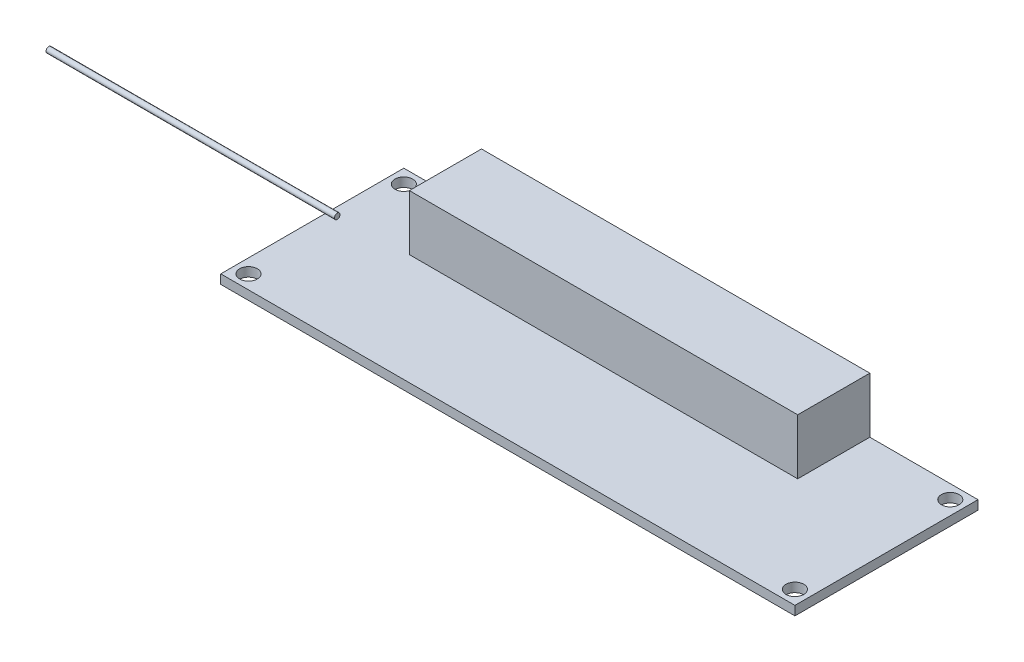
from build123d import *

# Parameters (mm, degrees)
SKIZZE1_W                            = 103.5
SKIZZE1_H                            = 33
AUFSATZ_LINEAR_AUSTRAGEN1_DEPTH      = 1.65
SKIZZE3_R                            = 0.5
AUFSATZ_LINEAR_AUSTRAGEN2_DEPTH      = 50
AUFSATZ_LINEAR_AUSTRAGEN2_DEPTH_BACK = 2
SKIZZE4_W                            = 70
SKIZZE4_H                            = 13
AUFSATZ_LINEAR_AUSTRAGEN3_DEPTH      = 10
SKIZZE6_R                            = 1.6
SCHNITT_LINEAR_AUSTRAGEN1_DEPTH      = 2.65


with BuildPart() as part:
    # Skizze1 → Aufsatz-Linear austragen1 (new body)
    with BuildSketch(Plane(origin=(0, 0, 0), x_dir=(1, 0, 0), z_dir=(0, 1, 0))):
        Rectangle(SKIZZE1_W, SKIZZE1_H)
    extrude(amount=AUFSATZ_LINEAR_AUSTRAGEN1_DEPTH)

    # Skizze4 → Aufsatz-Linear austragen3 (add)
    with BuildSketch(Plane(origin=(0, 1.65, 0), x_dir=(1, 0, 0), z_dir=(0, 1, 0))):
        with Locations((-2.75, 10)):
            Rectangle(SKIZZE4_W, SKIZZE4_H)
    extrude(amount=AUFSATZ_LINEAR_AUSTRAGEN3_DEPTH)

    # Skizze6 → Schnitt-Linear austragen1 (cut, through all)
    with BuildSketch(Plane(origin=(0, 1.65, 0), x_dir=(1, 0, 0), z_dir=(0, 1, 0))):
        with Locations((-49.25, 14)):
            Circle(SKIZZE6_R)
        with Locations((49.25, 14)):
            Circle(SKIZZE6_R)
        with Locations((49.25, -14)):
            Circle(SKIZZE6_R)
        with Locations((-49.25, -14)):
            Circle(SKIZZE6_R)
    extrude(amount=-SCHNITT_LINEAR_AUSTRAGEN1_DEPTH, mode=Mode.SUBTRACT)


with BuildPart() as body_2:
    # Skizze3 → Aufsatz-Linear austragen2 (new body, two sides)
    with BuildSketch(Plane.ZY.offset(51.75)) as aufsatz_linear_austragen2_sk:
        with Locations((-2.5, 2.15)):
            Circle(SKIZZE3_R)
    extrude(amount=AUFSATZ_LINEAR_AUSTRAGEN2_DEPTH)
    extrude(aufsatz_linear_austragen2_sk.sketch, amount=-AUFSATZ_LINEAR_AUSTRAGEN2_DEPTH_BACK)


solid = Compound([part.part, body_2.part])
